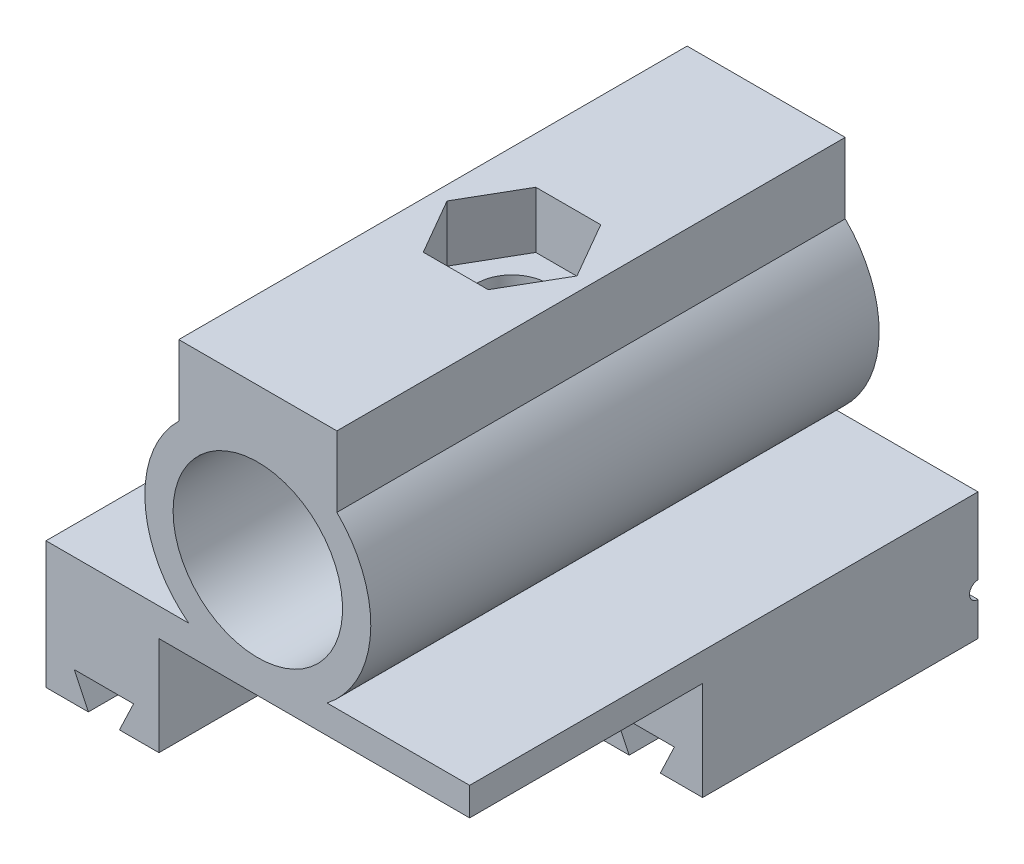
from build123d import *

# Parameters (mm, degrees)
SKETCH1_W           = 30
SKETCH1_H           = 36
BOSS_EXTRUDE1_DEPTH = 9
CUT_EXTRUDE1_DEPTH  = 37
SKETCH3_W           = 22
SKETCH3_H           = 7
CUT_EXTRUDE2_DEPTH  = 16.5
SKETCH4_W           = 14
SKETCH4_H           = 7
CUT_EXTRUDE3_DEPTH  = 20.5
BOSS_EXTRUDE4_DEPTH = 36
SKETCH6_R           = 6
CUT_EXTRUDE4_DEPTH  = 37
CUT_EXTRUDE8_DEPTH  = 4
SKETCH8_R           = 2.5
CUT_EXTRUDE9_DEPTH  = 3
SKETCH9_R           = 0.6
CUT_EXTRUDE10_DEPTH = 31


with BuildPart() as part:
    # Sketch1 → Boss-Extrude1 (new body)
    with BuildSketch(Plane(origin=(0, 0, 0), x_dir=(1, 0, 0), z_dir=(0, 1, 0))):
        Rectangle(SKETCH1_W, SKETCH1_H)
    extrude(amount=BOSS_EXTRUDE1_DEPTH)

    # Sketch2 → Cut-Extrude1 (cut, through all)
    with BuildSketch(Plane.XY.offset(18)):
        Polygon((-12, 0), (-13, 2.1), (-8.8, 2.1), (-9.8, 0), align=None)
        Polygon((12, 0), (13, 2.1), (8.8, 2.1), (9.8, 0), align=None)
    extrude(amount=-CUT_EXTRUDE1_DEPTH, mode=Mode.SUBTRACT)

    # Sketch3 → Cut-Extrude2 (cut)
    with BuildSketch(Plane.XY.offset(18)):
        with Locations((4, 3.5)):
            Rectangle(SKETCH3_W, SKETCH3_H)
    extrude(amount=-CUT_EXTRUDE2_DEPTH, mode=Mode.SUBTRACT)

    # Sketch4 → Cut-Extrude3 (cut, through all)
    with BuildSketch(Plane.XY.offset(1.5)):
        with Locations((0, 3.5)):
            Rectangle(SKETCH4_W, SKETCH4_H)
    extrude(amount=-CUT_EXTRUDE3_DEPTH, mode=Mode.SUBTRACT)

    # Sketch5 → Boss-Extrude4 (add)
    with BuildSketch(Plane.XY.offset(18)):
        with BuildLine():
            Line((-4.898979486, 9), (4.898979486, 9))
            ThreePointArc((4.898979486, 9), (7.986516373, 14.860274987), (5.598833698, 21.038841035))
            Line((5.598833698, 21.038841035), (5.598833698, 26.038841035))
            Line((5.598833698, 26.038841035), (-5.598833698, 26.038841035))
            Line((-5.598833698, 26.038841035), (-5.598833698, 21.038841035))
            ThreePointArc((-5.598833698, 21.038841035), (-7.986516373, 14.860274987), (-4.898979486, 9))
        make_face()
    extrude(amount=-BOSS_EXTRUDE4_DEPTH)

    # Sketch6 → Cut-Extrude4 (cut, through all)
    with BuildSketch(Plane(origin=(0, 0, -18), x_dir=(-1, 0, 0), z_dir=(0, 0, -1))):
        with Locations((0, 15.32455532)):
            Circle(SKETCH6_R)
    extrude(amount=-CUT_EXTRUDE4_DEPTH, mode=Mode.SUBTRACT)

    # Sketch7 → Cut-Extrude8 (cut)
    with BuildSketch(Plane(origin=(0, 26.038841035, 0), x_dir=(1, 0, 0), z_dir=(0, 1, 0))):
        Polygon((2.3, -3.983716857), (4.6, 0), (2.3, 3.983716857), (-2.3, 3.983716857), (-4.6, 0), (-2.3, -3.983716857), align=None)
    extrude(amount=-CUT_EXTRUDE8_DEPTH, mode=Mode.SUBTRACT)

    # Sketch8 → Cut-Extrude9 (cut)
    with BuildSketch(Plane(origin=(0, 22.038841035, 0), x_dir=(1, 0, 0), z_dir=(0, 1, 0))):
        Circle(SKETCH8_R)
    extrude(amount=-CUT_EXTRUDE9_DEPTH, mode=Mode.SUBTRACT)

    # Sketch9 → Cut-Extrude10 (cut, through all)
    with BuildSketch(Plane.ZY.offset(15)):
        with Locations((-18, 3)):
            Circle(SKETCH9_R)
    extrude(amount=-CUT_EXTRUDE10_DEPTH, mode=Mode.SUBTRACT)


solid = part.part
